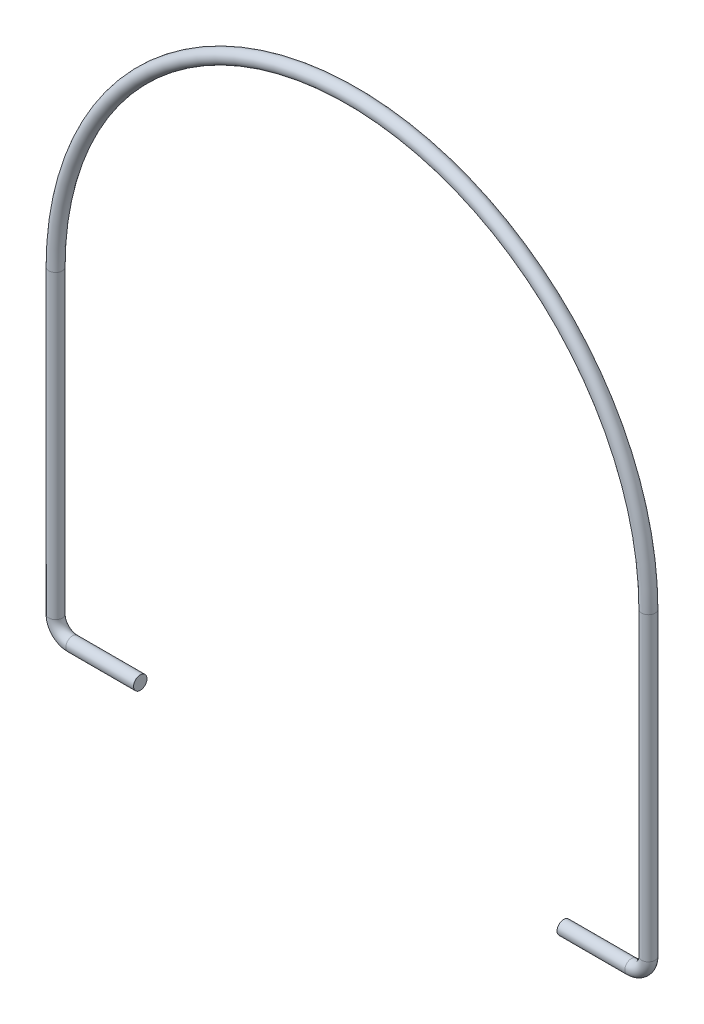
from build123d import *

# Parameters (mm, degrees)
SKETCH2_R = 1.5875


with BuildPart() as part:
    # Sweep1: sweep along a path in Sketch1
    with BuildLine(Plane.XY) as sweep1_path:
        Line((0, 0), (-16, 0))
        ThreePointArc((-16, 0), (-18.828427125, 1.171572875), (-20, 4))
        Line((-20, 4), (-20, 75))
        ThreePointArc((-20, 75), (50, 145), (120, 75))
        Line((120, 75), (120, 4))
        ThreePointArc((120, 4), (118.828427125, 1.171572875), (116, 0))
        Line((116, 0), (100, 0))
    # Sketch2 → Sweep1 (sweep)
    with BuildSketch(Plane(origin=(0, 0, 0), x_dir=(0, 0, -1), z_dir=(1, 0, 0))):
        Circle(SKETCH2_R)
    sweep(path=sweep1_path.line)


solid = part.part
